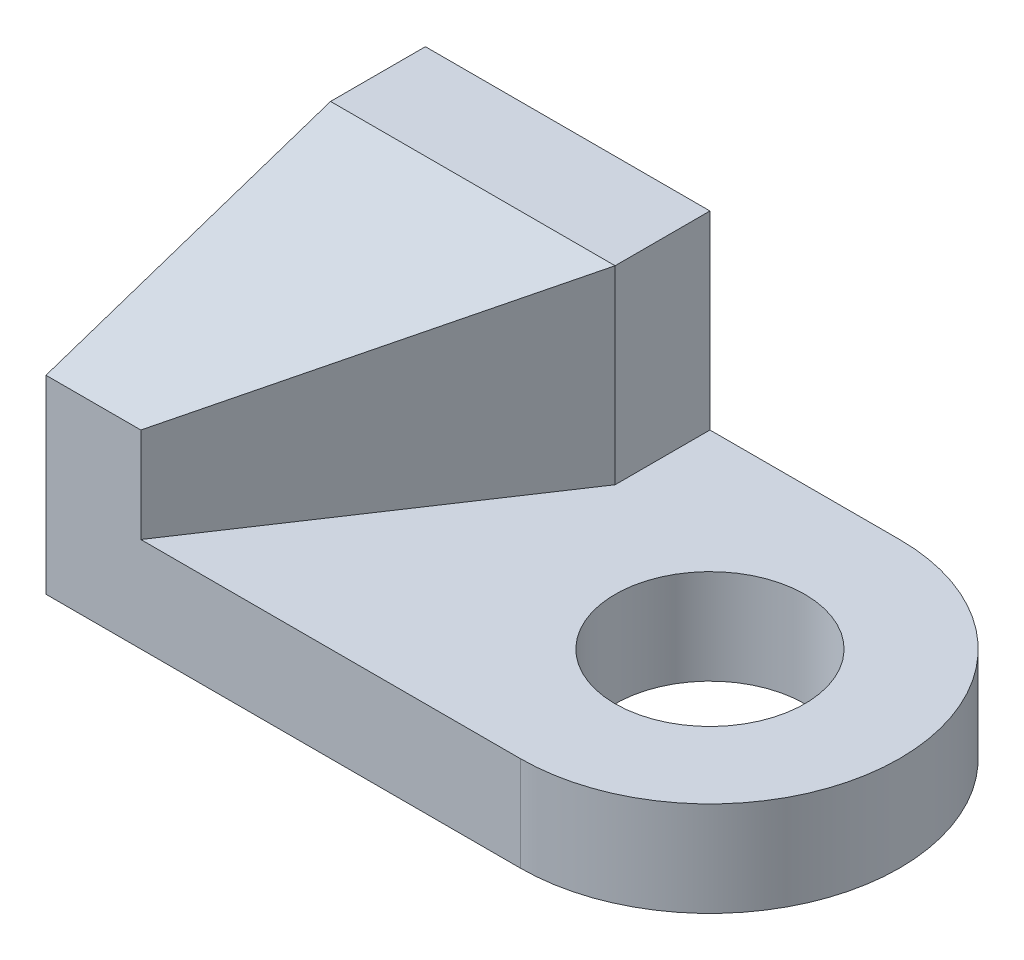
from build123d import *

# Parameters (mm, degrees)
SKETCH_1_R          = 5
EXTRUDE_1_DEPTH     = 5
SKETCH_1_3_W        = 15
SKETCH_1_3_H        = 20
EXTRUDE_2_DEPTH     = 15
CUT_EXTRUDE_1_DEPTH = 15
CUT_EXTRUDE_2_DEPTH = 10
SCALE_1_SCALE       = 0.2


with BuildPart() as part:
    # 草圖1 → 填料-伸長1 (new body)
    with BuildSketch(Plane(origin=(0, 0, 0), x_dir=(1, 0, 0), z_dir=(0, 1, 0))):
        with BuildLine():
            ThreePointArc((0, -10), (10, 0), (0, 10))
            Line((0, 10), (-10, 10))
            Line((-10, 10), (-10, 5))
            Line((-10, 5), (-10, -10))
            Line((-10, -10), (0, -10))
        make_face()
        Circle(SKETCH_1_R, mode=Mode.SUBTRACT)
    extrude(amount=EXTRUDE_1_DEPTH)

    # 草圖1<3> → 填料-伸長2 (add)
    with BuildSketch(Plane(origin=(0, 0, 0), x_dir=(1, 0, 0), z_dir=(0, 1, 0))):
        with Locations((-17.5, 0)):
            Rectangle(SKETCH_1_3_W, SKETCH_1_3_H)
    extrude(amount=EXTRUDE_2_DEPTH)

    # 草圖3 → 除料-伸長1 (cut)
    with BuildSketch(Plane(origin=(-10, 0, 0), x_dir=(0, 0, -1), z_dir=(1, 0, 0))):
        Polygon((5, 15), (-10, 10), (-10, 15), align=None)
    extrude(amount=-CUT_EXTRUDE_1_DEPTH, mode=Mode.SUBTRACT)

    # 草圖2 → 除料-伸長2 (cut)
    with BuildSketch(Plane(origin=(0, 15, 0), x_dir=(1, 0, 0), z_dir=(0, 1, 0))):
        Polygon((-10, 5), (-20, -10), (-10, -10), align=None)
    extrude(amount=-CUT_EXTRUDE_2_DEPTH, mode=Mode.SUBTRACT)


with BuildPart() as part_1:
    # 縮放比例1: scaled about (-13.252128035, 5.281976431, -1.035154021)
    add(part.part.scale(SCALE_1_SCALE).moved(Location((-10.601702428, 4.225581145, -0.828123217))))


solid = part_1.part
